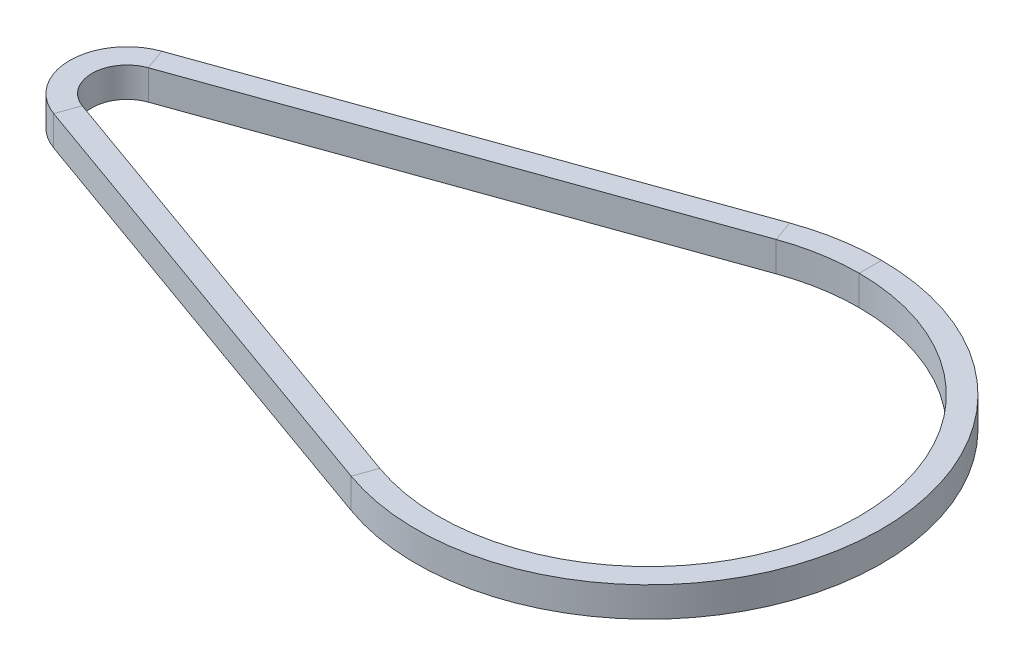
from build123d import *

# Parameters (mm, degrees)
SKETCH2_W = 3
SKETCH2_H = 4


with BuildPart() as part:
    # Sweep1: sweep along a path in Sketch1
    with BuildLine(Plane(origin=(0, 0, 0), x_dir=(1, 0, 0), z_dir=(0, 1, 0))) as sweep1_path:
        Line((-1.580542857, 4.426272052), (60.503291429, 26.595302711))
        ThreePointArc((60.503291429, 26.595302711), (98.24, 0), (60.503291429, -26.595302711))
        Line((60.503291429, -26.595302711), (-1.580542857, -4.426272052))
        ThreePointArc((-1.580542857, -4.426272052), (-4.7, 0), (-1.580542857, 4.426272052))
    # Sketch2 → Sweep1 (sweep)
    with BuildSketch(Plane(origin=(70, 0, 0), x_dir=(0, 0, -1), z_dir=(1, 0, 0))):
        with Locations((29.74, 0)):
            Rectangle(SKETCH2_W, SKETCH2_H)
    sweep(path=sweep1_path.line)


solid = part.part
